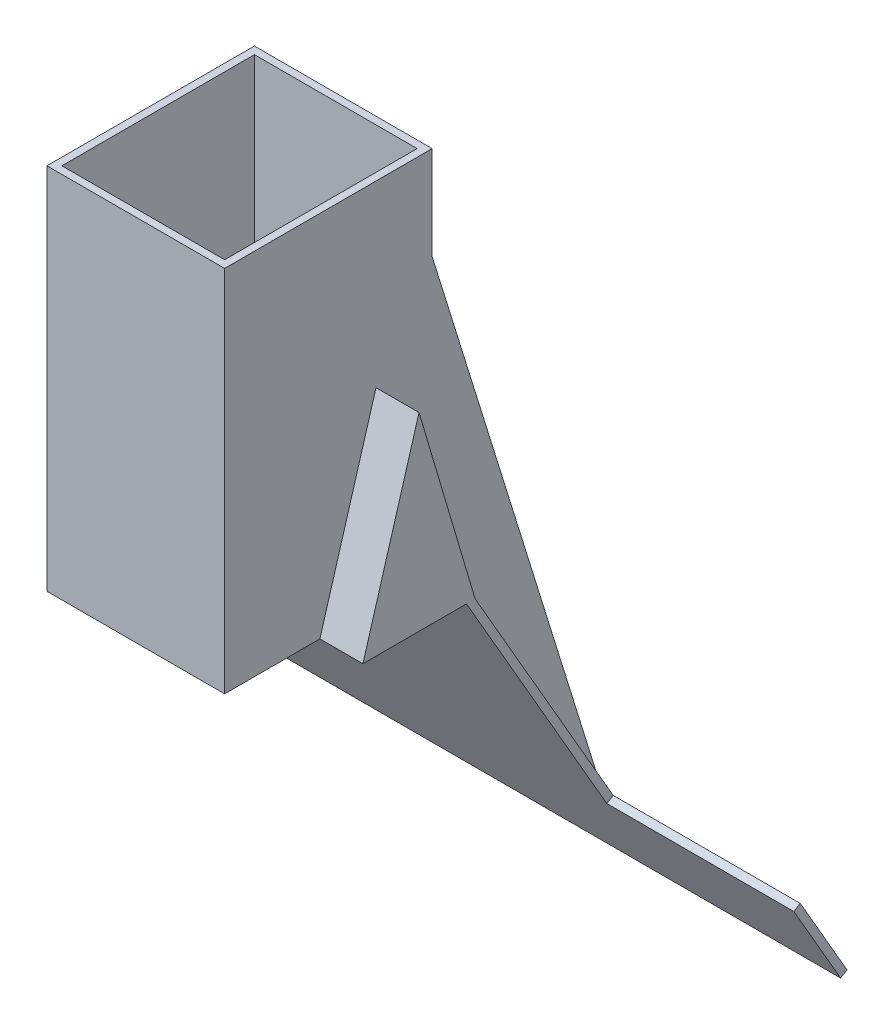
from build123d import *

# Parameters (mm, degrees)
SKIZZE1_W                       = 9.5
SKIZZE1_H                       = 11.093
SKIZZE1_W_2                     = 8.7
SKIZZE1_H_2                     = 4.7
SKIZZE1_H_3                     = 5.193
AUFSATZ_LINEAR_AUSTRAGEN1_DEPTH = 19.7
AUFSATZ_LINEAR_AUSTRAGEN2_DEPTH = 2.3
SCHNITT_LINEAR_AUSTRAGEN1_DEPTH = 13.7
SKIZZE4_W                       = 13.3
SKIZZE4_H                       = 5.193
SCHNITT_LINEAR_AUSTRAGEN2_DEPTH = 0.4
AUFSATZ_LINEAR_AUSTRAGEN3_DEPTH = 14.1
AUFSATZ_LINEAR_START            = -9.5
AUFSATZ_LINEAR_AUSTRAGEN4_DEPTH = 9.5
SCHNITT_LINEAR_AUSTRAGEN3_REACH = 39.021
SKIZZE7_W                       = 8.7
SKIZZE7_H                       = 0.4
SKIZZE8_W                       = 10
SKIZZE8_H                       = 5
AUFSATZ_LINEAR_AUSTRAGEN5_DEPTH = 0.4


with BuildPart() as part:
    # Skizze1 → Aufsatz-Linear austragen1 (new body)
    with BuildSketch(Plane(origin=(0, 0, 0), x_dir=(1, 0, 0), z_dir=(0, 1, 0))):
        with Locations((4.75, 5.5465)):
            Rectangle(SKIZZE1_W, SKIZZE1_H)
        with Locations((4.75, 2.75)):
            Rectangle(SKIZZE1_W_2, SKIZZE1_H_2, mode=Mode.SUBTRACT)
        with Locations((4.75, 8.0965)):
            Rectangle(SKIZZE1_W_2, SKIZZE1_H_3, mode=Mode.SUBTRACT)
    extrude(amount=AUFSATZ_LINEAR_AUSTRAGEN1_DEPTH)

    # Skizze2 → Aufsatz-Linear austragen2 (add)
    with BuildSketch(Plane.ZY):
        Polygon((-11.093, 0), (-8.093, 10.13), (-5.093, 0), align=None)
    aufsatz_linear_austragen2 = extrude(amount=AUFSATZ_LINEAR_AUSTRAGEN2_DEPTH)

    # Spiegeln1: Aufsatz-Linear austragen2 across plane
    add(aufsatz_linear_austragen2.mirror(Plane(origin=(4.75, 0, 0), x_dir=(0, 0, 1), z_dir=(1, 0, 0))))

    # Skizze3 → Schnitt-Linear austragen1 (cut)
    with BuildSketch(Plane.ZY.offset(2.3)):
        Polygon((-10.379677593, 1), (-5.806322407, 1), (-8.093, 8.721348004), align=None)
    extrude(amount=-SCHNITT_LINEAR_AUSTRAGEN1_DEPTH, mode=Mode.SUBTRACT)

    # Skizze4 → Schnitt-Linear austragen2 (cut)
    with BuildSketch(Plane.XZ):
        with Locations((4.75, -8.0965)):
            Rectangle(SKIZZE4_W, SKIZZE4_H)
    extrude(amount=-SCHNITT_LINEAR_AUSTRAGEN2_DEPTH, mode=Mode.SUBTRACT)

    # Skizze5 → Aufsatz-Linear austragen3 (add)
    with BuildSketch(Plane.ZY.offset(2.3)):
        Polygon((-20.977529946, -17.120508076), (-20.631119785, -17.320508076), (-10.631119785, 0), (-11.093, 0), align=None)
    extrude(amount=-AUFSATZ_LINEAR_AUSTRAGEN3_DEPTH)

    # Skizze6 → Aufsatz-Linear austragen4 (add)
    with BuildSketch(Plane.ZY.offset(AUFSATZ_LINEAR_START)):
        Polygon((-20.977529946, -17.120508076), (-11.093, 0), (-11.093, 14.7), align=None)
    extrude(amount=AUFSATZ_LINEAR_AUSTRAGEN4_DEPTH)

    # Skizze7 → Schnitt-Linear austragen3 (cut, up to next)
    with BuildSketch(Plane(origin=(0, 19.7, 0), x_dir=(1, 0, 0), z_dir=(0, 1, 0)), mode=Mode.PRIVATE) as schnitt_linear_austragen3_sk1:
        with Locations((4.75, 5.3)):
            Rectangle(SKIZZE7_W, SKIZZE7_H)
    schnitt_linear_austragen3_tool1 = extrude(schnitt_linear_austragen3_sk1.sketch, amount=-SCHNITT_LINEAR_AUSTRAGEN3_REACH, mode=Mode.PRIVATE) & part.part
    add(schnitt_linear_austragen3_tool1.solids().sort_by_distance((4.75, 19.7, -5.3))[0], mode=Mode.SUBTRACT)

    # Skizze8 → Aufsatz-Linear austragen5 (add)
    with BuildSketch(Plane(origin=(0, 4.603409902, -7.973339838), x_dir=(1, 0, 0), z_dir=(0, -0.5, 0.866025404))):
        with Locations((-7.3, -22.815559892)):
            Rectangle(SKIZZE8_W, SKIZZE8_H)
        with Locations((16.8, -22.815559892)):
            Rectangle(SKIZZE8_W, SKIZZE8_H)
    extrude(amount=-AUFSATZ_LINEAR_AUSTRAGEN5_DEPTH)


solid = part.part
